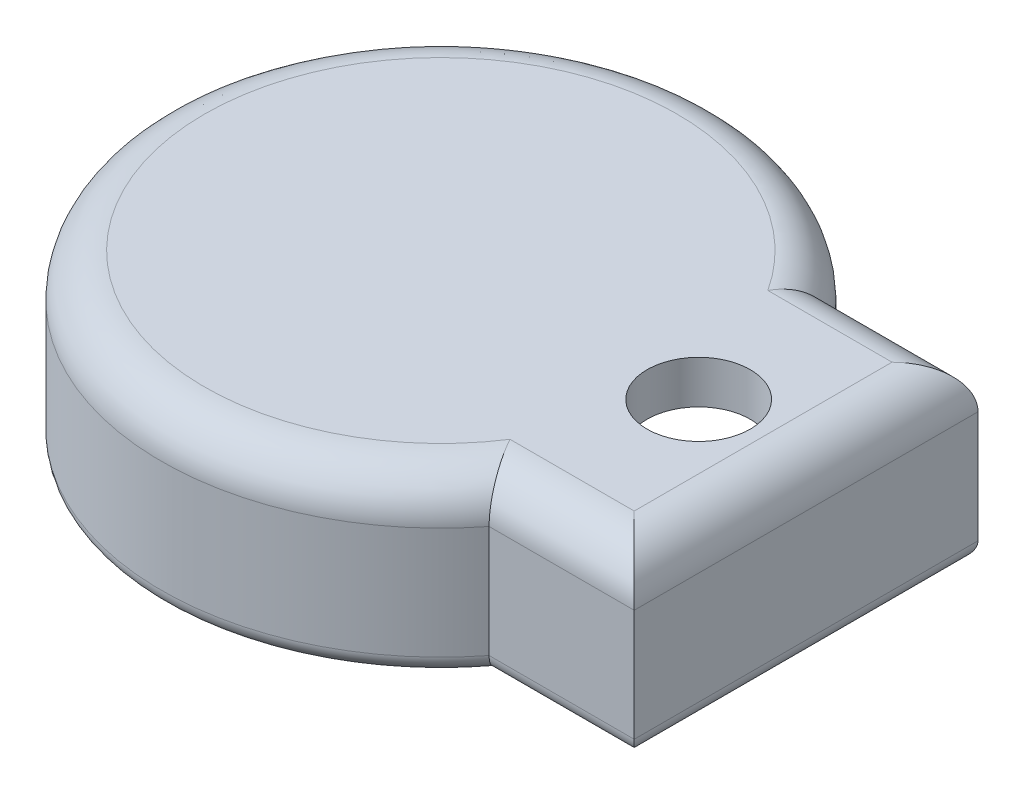
from build123d import *

# Parameters (mm, degrees)
BOSS_EXTRU_1_DEPTH = 15
ESQUISSE2_R        = 6
BOSS_EXTRU_2_DEPTH = 5
CONG_1_R           = 5
CONG_2_R           = 2


with BuildPart() as part:
    # Esquisse1 → Boss.-Extru.1 (new body)
    with BuildSketch(Plane(origin=(0, 0, 0), x_dir=(1, 0, 0), z_dir=(0, 1, 0))):
        with BuildLine():
            ThreePointArc((28.831406487, 15), (27.338937497, 17.573630715), (25.617376915, 20))
            ThreePointArc((25.617376915, 20), (-32.5, 0), (25.617376915, -20))
            ThreePointArc((25.617376915, -20), (27.338937497, -17.573630715), (28.831406487, -15))
            Line((28.831406487, -15), (23.048861143, -15))
            ThreePointArc((23.048861143, -15), (-27.5, 0), (23.048861143, 15))
            Line((23.048861143, 15), (28.831406487, 15))
        make_face()
        with BuildLine():
            Line((42.5, 20), (25.617376915, 20))
            ThreePointArc((25.617376915, 20), (27.338937497, 17.573630715), (28.831406487, 15))
            Line((28.831406487, 15), (37.5, 15))
            Line((37.5, 15), (37.5, -15))
            Line((37.5, -15), (28.831406487, -15))
            ThreePointArc((28.831406487, -15), (27.338937497, -17.573630715), (25.617376915, -20))
            Line((25.617376915, -20), (42.5, -20))
            Line((42.5, -20), (42.5, 20))
        make_face()
    extrude(amount=BOSS_EXTRU_1_DEPTH)

    # Esquisse2 → Boss.-Extru.2 (add)
    with BuildSketch(Plane(origin=(0, 15, 0), x_dir=(1, 0, 0), z_dir=(0, 1, 0))):
        with BuildLine():
            Line((42.5, 20), (25.617376915, 20))
            ThreePointArc((25.617376915, 20), (-32.5, 0), (25.617376915, -20))
            Line((25.617376915, -20), (42.5, -20))
            Line((42.5, -20), (42.5, 20))
        make_face()
        with Locations((30, 0)):
            Circle(ESQUISSE2_R, mode=Mode.SUBTRACT)
    extrude(amount=BOSS_EXTRU_2_DEPTH)

    # Congé1
    cong_1_edges = [part.edges().sort_by_distance(p)[0] for p in [
        (42.5, 20, 0),
        (34.058688457, 20, -20),
        (-32.5, 20, 0),
        (34.058688457, 20, 20),
    ]]
    fillet(cong_1_edges, radius=CONG_1_R)

    # Congé2
    cong_2_edges = [part.edges().sort_by_distance(p)[0] for p in [
        (-27.5, 0, 0),
        (30.274430572, 0, 15),
        (37.5, 0, 0),
        (30.274430572, 0, -15),
        (42.5, 0, 0),
        (34.058688457, 0, 20),
        (-32.5, 0, 0),
        (34.058688457, 0, -20),
    ]]
    fillet(cong_2_edges, radius=CONG_2_R)


solid = part.part
